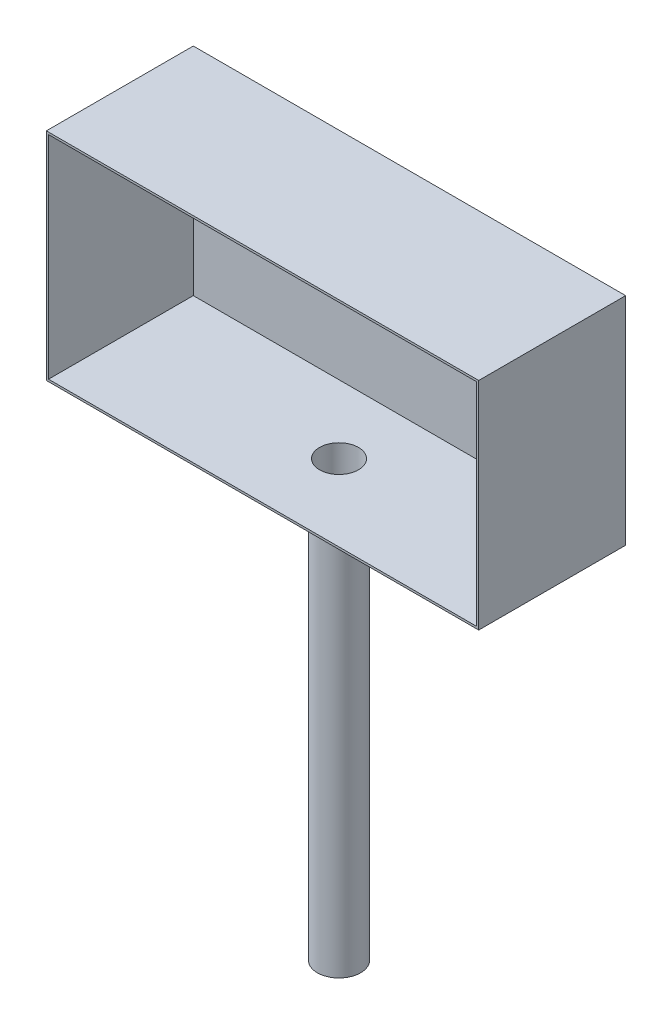
from build123d import *

# Parameters (mm, degrees)
SKETCH2_R           = 100
BOSS_EXTRUDE1_DEPTH = 2000
BOSS_EXTRUDE2_DEPTH = 1000
SHELL1_T            = -10


with BuildPart() as part:
    # Sketch2 → Boss-Extrude1 (new body)
    with BuildSketch(Plane(origin=(0, 0, 0), x_dir=(1, 0, 0), z_dir=(0, 1, 0))):
        Circle(SKETCH2_R)
    extrude(amount=BOSS_EXTRUDE1_DEPTH)

    # Sketch3 → Boss-Extrude2 (add, symmetric)
    with BuildSketch(Plane(origin=(0, 0, 0), x_dir=(0, 0, -1), z_dir=(1, 0, 0))):
        Polygon((0, 2000), (-353.719295441, 2000), (-353.719295441, 3000), (325.945022222, 3000), (325.945022222, 2000), align=None)
    extrude(amount=BOSS_EXTRUDE2_DEPTH, both=True)

    # Shell1
    shell1_openings = [part.faces().sort_by_distance(p)[0] for p in [
        (0, 2500, 353.719295441),
    ]]
    offset(amount=SHELL1_T, openings=shell1_openings, kind=Kind.INTERSECTION)


solid = part.part
